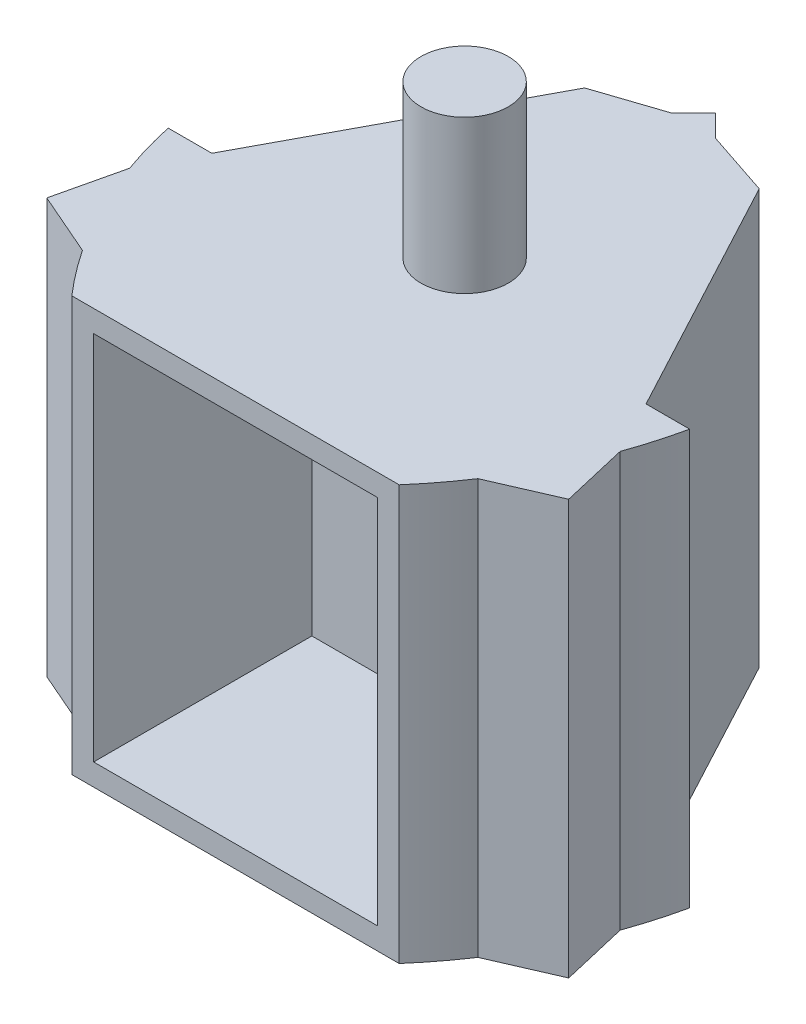
from build123d import *

# Parameters (mm, degrees)
BOSS_EXTRUDE1_DEPTH = 19
BOSS_EXTRUDE2_DEPTH = 7
BOSS_EXTRUDE3_DEPTH = 7
BOSS_EXTRUDE4_DEPTH = 19
CUT_EXTRUDE1_DEPTH  = 19
CUT_EXTRUDE2_DEPTH  = 19
BOSS_EXTRUDE5_DEPTH = 19
BOSS_EXTRUDE6_DEPTH = 19
BOSS_EXTRUDE7_DEPTH = 19
BOSS_EXTRUDE8_DEPTH = 19
BOSS_EXTRUDE9_DEPTH = 19
SKETCH14_W          = 13
SKETCH14_H          = 17
CUT_EXTRUDE3_DEPTH  = 10


with BuildPart() as part:
    # Sketch1 → Boss-Extrude1 (new body)
    with BuildSketch(Plane(origin=(0, 0, 0), x_dir=(1, 0, 0), z_dir=(0, 1, 0))):
        Polygon((4, 0), (7.5, -20), (-7.5, -20), (-4, 0), align=None)
        Polygon((-7.5, -20), (-5.948577014, -11.134725796), (-10.948577014, -11.134725796), (-9.949358248, -13.703422483), (-9.224288507, -15.567362898), (-8.499218766, -17.431303313), align=None)
        Polygon((-9.224288507, -15.567362898), (-9.949358248, -13.703422483), (-11.088228922, -16.292432639), align=None)
        Polygon((-11.088228922, -16.292432639), (-8.499218766, -17.431303313), (-9.224288507, -15.567362898), align=None)
        Polygon((5.948577014, -11.134725796), (7.5, -20), (8.499218766, -17.431303313), (9.224288507, -15.567362898), (9.949358248, -13.703422483), (10.948577014, -11.134725796), align=None)
        Polygon((9.949358248, -13.703422483), (9.224288507, -15.567362898), (11.088228922, -16.292432639), align=None)
        Polygon((9.224288507, -15.567362898), (8.499218766, -17.431303313), (11.088228922, -16.292432639), align=None)
        Polygon((0, 1), (-2, 0), (2, 0), align=None)
    extrude(amount=BOSS_EXTRUDE1_DEPTH)

    # Sketch2 → Boss-Extrude2 (add)
    with BuildSketch(Plane(origin=(0, 19, 0), x_dir=(1, 0, 0), z_dir=(0, 1, 0))):
        with BuildLine():
            ThreePointArc((2, -9.5), (1.414213562, -8.085786438), (0, -7.5))
            Line((0, -7.5), (0, -11.5))
            ThreePointArc((0, -11.5), (1.414213562, -10.914213562), (2, -9.5))
        make_face()
        with BuildLine():
            Line((0, -11.5), (0, -7.5))
            ThreePointArc((0, -7.5), (-2, -9.5), (0, -11.5))
        make_face()
    extrude(amount=BOSS_EXTRUDE2_DEPTH)

    # Sketch3 → Boss-Extrude3 (add)
    with BuildSketch(Plane.XZ):
        with BuildLine():
            ThreePointArc((0, 11.5), (-2, 9.5), (0, 7.5))
            Line((0, 7.5), (0, 11.5))
        make_face()
        with BuildLine():
            Line((0, 11.5), (0, 7.5))
            ThreePointArc((0, 7.5), (1.414213562, 8.085786438), (2, 9.5))
            ThreePointArc((2, 9.5), (1.414213562, 10.914213562), (0, 11.5))
        make_face()
    extrude(amount=BOSS_EXTRUDE3_DEPTH)

    # Sketch4 → Boss-Extrude4 (add)
    with BuildSketch(Plane.XZ):
        Polygon((9.948577014, 11.134725796), (4, 0), (5.948577014, 11.134725796), align=None)
        Polygon((-5.948577014, 11.134725796), (-9.948577014, 11.134725796), (-4, 0), align=None)
    extrude(amount=-BOSS_EXTRUDE4_DEPTH)

    # Sketch5 → Cut-Extrude1 (cut)
    with BuildSketch(Plane.XZ):
        Polygon((9.949358248, 13.703422483), (8.499218766, 17.431303313), (11.088228922, 16.292432639), align=None)
    extrude(amount=-CUT_EXTRUDE1_DEPTH, mode=Mode.SUBTRACT)

    # Sketch6 → Cut-Extrude2 (cut)
    with BuildSketch(Plane.XZ):
        Polygon((-9.949358248, 13.703422483), (-8.499218766, 17.431303313), (-11.088228922, 16.292432639), align=None)
    extrude(amount=-CUT_EXTRUDE2_DEPTH, mode=Mode.SUBTRACT)

    # Sketch7 → Boss-Extrude5 (add)
    with BuildSketch(Plane.XZ):
        Polygon((10.948577014, 11.134725796), (11.948577014, 11.134725796), (7.5, 20), align=None)
        Polygon((-11.948577014, 11.134725796), (-7.5, 20), (-10.948577014, 11.134725796), align=None)
    extrude(amount=-BOSS_EXTRUDE5_DEPTH)

    # Sketch8 → Boss-Extrude6 (add)
    with BuildSketch(Plane.XZ):
        Polygon((2, 0), (0, -2), (-2, 0), (0, -1), align=None)
    extrude(amount=-BOSS_EXTRUDE6_DEPTH)

    # Sketch9 → Boss-Extrude7 (add)
    with BuildSketch(Plane.XZ):
        Polygon((-1, -1), (-4, 0), (-2, 0), align=None)
        Polygon((1, -1), (4, 0), (2, 0), align=None)
    extrude(amount=-BOSS_EXTRUDE7_DEPTH)

    # Sketch10 → Boss-Extrude8 (add)
    with BuildSketch(Plane.XZ):
        Polygon((11.069784798, 12.886012542), (11.958747137, 16.688609807), (8.378792216, 18.248713254), align=None)
        Polygon((-8.378792216, 18.248713254), (-11.069784798, 12.886012542), (-11.958747137, 16.688609807), align=None)
    extrude(amount=-BOSS_EXTRUDE8_DEPTH)

    # Sketch13 → Boss-Extrude9 (add)
    with BuildSketch(Plane.XZ):
        with BuildLine():
            Line((11.069784798, 12.886012542), (11.948577014, 11.134725796))
            ThreePointArc((11.948577014, 11.134725796), (11.633851427, 12.384363188), (11.239303029, 13.61113838))
            Line((11.239303029, 13.61113838), (11.069784798, 12.886012542))
        make_face()
        with BuildLine():
            Line((7.5, 20), (8.378792216, 18.248713254))
            Line((8.378792216, 18.248713254), (9.061461884, 17.951213613))
            ThreePointArc((9.061461884, 17.951213613), (8.313750457, 19.000772297), (7.5, 20))
        make_face()
        with BuildLine():
            Line((-9.061461884, 17.951213613), (-8.378792216, 18.248713254))
            Line((-8.378792216, 18.248713254), (-7.5, 20))
            ThreePointArc((-7.5, 20), (-8.313750457, 19.000772297), (-9.061461884, 17.951213613))
        make_face()
        with BuildLine():
            ThreePointArc((-11.239303029, 13.61113838), (-11.633851427, 12.384363188), (-11.948577014, 11.134725796))
            Line((-11.948577014, 11.134725796), (-11.069784798, 12.886012542))
            Line((-11.069784798, 12.886012542), (-11.239303029, 13.61113838))
        make_face()
    extrude(amount=-BOSS_EXTRUDE9_DEPTH)

    # Sketch14 → Cut-Extrude3 (cut)
    with BuildSketch(Plane.XY.offset(20)):
        with Locations((0, 9.5)):
            Rectangle(SKETCH14_W, SKETCH14_H)
    extrude(amount=-CUT_EXTRUDE3_DEPTH, mode=Mode.SUBTRACT)


solid = part.part
